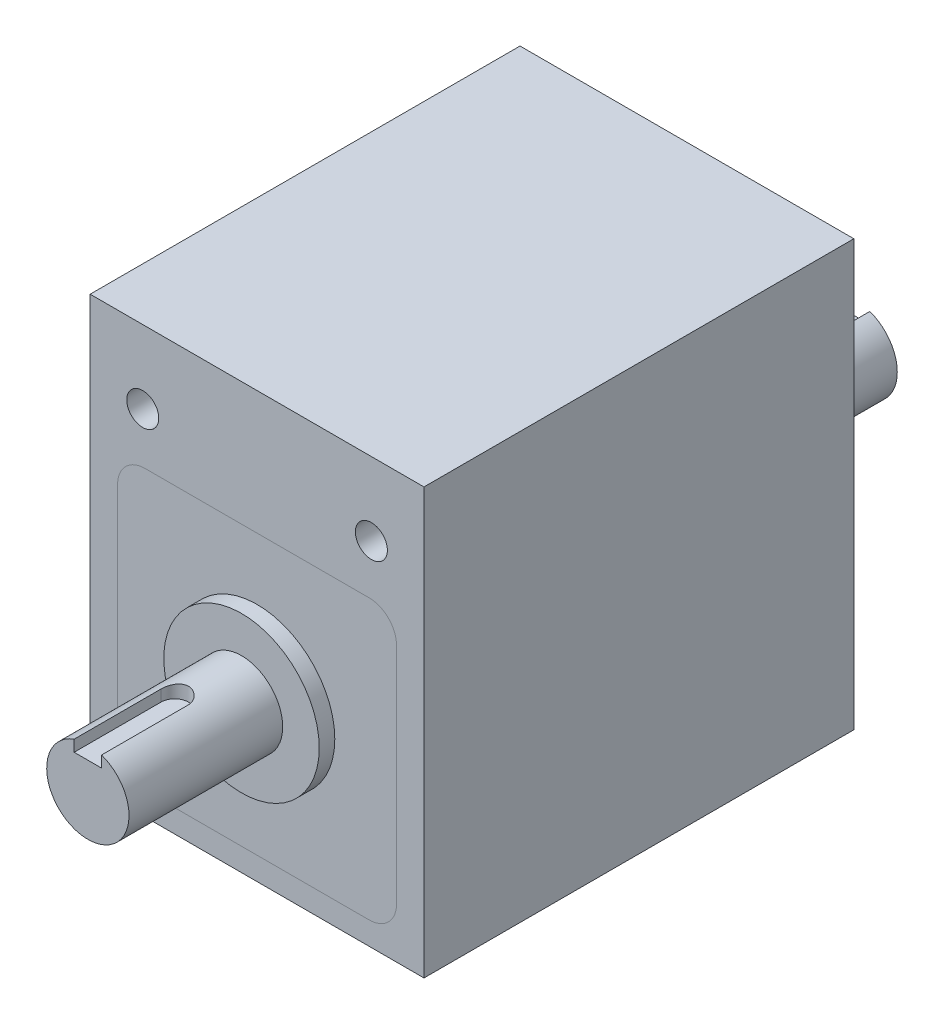
from build123d import *

# Parameters (mm, degrees)
SKETCH1_W                      = 73
SKETCH1_H                      = 93
BOSS_EXTRUDE1_DEPTH            = 47
SKETCH2_R                      = 17
BOSS_EXTRUDE2_DEPTH            = 3.4
SKETCH3_R                      = 9
BOSS_EXTRUDE3_DEPTH            = 33.6
SKETCH4_R                      = 3
CUT_EXTRUDE1_DEPTH             = 3
M8X1_0_TAPPED_HOLE1_AT_2_COUNT = 2
M8X1_0_TAPPED_HOLE1_AT_2_PITCH = 50
M8X1_0_TAPPED_HOLE2_D          = 7
M8X1_0_TAPPED_HOLE2_DEPTH      = 19
M8X1_0_TAPPED_HOLE2_TIP        = 2.103012167


with BuildPart() as part:
    # Sketch1 → Boss-Extrude1 (new, symmetric)
    with BuildSketch(Plane.XY):
        with Locations((0, 11)):
            Rectangle(SKETCH1_W, SKETCH1_H)
    extrude(amount=BOSS_EXTRUDE1_DEPTH, both=True)

    # Sketch2 → Boss-Extrude2 (add)
    with BuildSketch(Plane.XY.offset(47)):
        Circle(SKETCH2_R)
    boss_extrude2 = extrude(amount=BOSS_EXTRUDE2_DEPTH)

    # Sketch3 → Boss-Extrude3 (add)
    with BuildSketch(Plane.XY.offset(50.4)):
        Circle(SKETCH3_R)
    boss_extrude3 = extrude(amount=BOSS_EXTRUDE3_DEPTH)

    # Sketch4 → Cut-Extrude1 (cut)
    with BuildSketch(Plane(origin=(0, 9, 0), x_dir=(1, 0, 0), z_dir=(0, 1, 0))):
        with BuildLine():
            ThreePointArc((3, -65), (0, -68), (-3, -65))
            Line((-3, -65), (-3, -84))
            Line((-3, -84), (3, -84))
            Line((3, -84), (3, -65))
        make_face()
        with Locations((0, -65)):
            Circle(SKETCH4_R)
    cut_extrude1 = extrude(amount=-CUT_EXTRUDE1_DEPTH, mode=Mode.SUBTRACT)

    # Sketch6 → M8x1.0 Tapped Hole1 (revolve, cut)
    with BuildSketch(Plane(origin=(-25, 41.5, 47), x_dir=(0, -1, 0), z_dir=(1, 0, 0))):
        Polygon((0, 0), (0, 10.103012167), (3.5, 8), (3.5, 0), align=None)
    m8x1_0_tapped_hole1 = revolve(axis=Axis((-25, 41.5, 53.35), (0, 0, -1)), mode=Mode.SUBTRACT)

    # M8x1.0 Tapped Hole1 at 2: M8x1.0 Tapped Hole1 ×2
    with Locations(*[(i * M8X1_0_TAPPED_HOLE1_AT_2_PITCH, 0, 0) for i in range(1, M8X1_0_TAPPED_HOLE1_AT_2_COUNT)]):
        add(m8x1_0_tapped_hole1, mode=Mode.SUBTRACT)

    # Mirror1: Boss-Extrude2, Boss-Extrude3, Cut-Extrude1, M8x1.0 Tapped Hole1 across plane
    add(boss_extrude2.mirror(Plane.XY))
    add(boss_extrude3.mirror(Plane.XY))
    add(cut_extrude1.mirror(Plane.XY), mode=Mode.SUBTRACT)
    add(m8x1_0_tapped_hole1.mirror(Plane.XY), mode=Mode.SUBTRACT)

    # Mirror1 copy 1 sketch → Mirror1 copy 1 (revolve, cut)
    with BuildSketch(Plane(origin=(25, 41.5, -47), x_dir=(0, -1, 0), z_dir=(1, 0, 0))):
        Polygon((0, 0), (0, -10.103012167), (3.5, -8), (3.5, 0), align=None)
    revolve(axis=Axis((25, 41.5, -53.35), (0, 0, -1)), mode=Mode.SUBTRACT)

    # M8x1.0 Tapped Hole2
    with Locations(Plane(origin=(26.5, -35.5, 26.5), x_dir=(0, 0, -1), z_dir=(0, -1, 0))):
        with Locations((0, 0), (53, 0), (53, -53), (0, -53)):
            Hole(M8X1_0_TAPPED_HOLE2_D / 2, depth=M8X1_0_TAPPED_HOLE2_DEPTH)
            with Locations((0, 0, -(M8X1_0_TAPPED_HOLE2_DEPTH + M8X1_0_TAPPED_HOLE2_TIP / 2))):  # 118° drill point
                Cone(0, M8X1_0_TAPPED_HOLE2_D / 2, M8X1_0_TAPPED_HOLE2_TIP, mode=Mode.SUBTRACT)


solid = part.part
